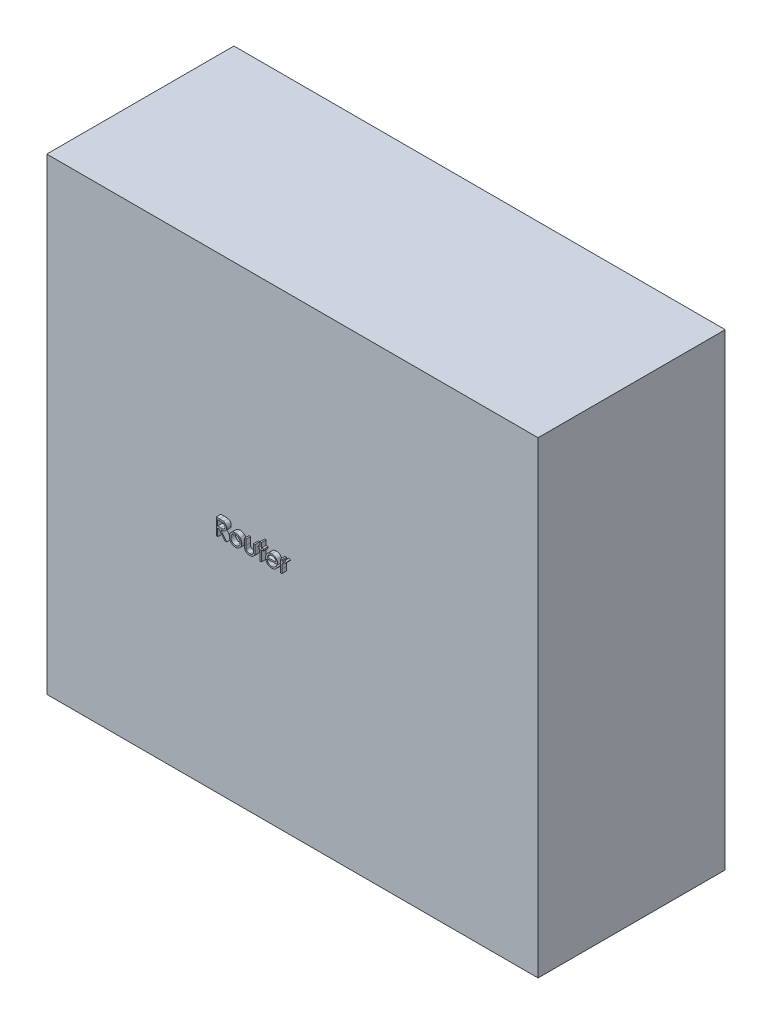
from build123d import *

# Parameters (mm, degrees)
SKETCH1_W           = 105
SKETCH1_H           = 100
BOSS_EXTRUDE1_DEPTH = 40
BOSS_EXTRUDE2_DEPTH = 1


with BuildPart() as part:
    # Sketch1 → Boss-Extrude1 (new body)
    with BuildSketch(Plane.XY):
        Rectangle(SKETCH1_W, SKETCH1_H)
    extrude(amount=BOSS_EXTRUDE1_DEPTH)

    # Sketch4 → Boss-Extrude2 (add)
    with BuildSketch(Plane.XY.offset(40)):
        with BuildLine():
            Line((-15.273233296, 1.946566312), (-14.572812623, 1.946566312))
            add(Edge.make_bspline(
                [(-14.572812623, 1.946566312), (-14.526071494, 1.946410726), (-14.43632335, 1.946111984), (-14.307750079, 1.944446221), (-14.190922982, 1.939671865), (-14.085903143, 1.935563282), (-13.992692488, 1.92807134), (-13.911005197, 1.920910693), (-13.8412175, 1.911537032), (-13.798971648, 1.902831609), (-13.779843873, 1.89889003)],
                knots=[0, 0, 0, 0, 0.000140226, 0.00026925, 0.000385712, 0.000490995, 0.000584507, 0.000666202, 0.000736998, 0.000795574, 0.000795574, 0.000795574, 0.000795574], degree=3))
            add(Edge.make_bspline(
                [(-13.779843873, 1.89889003), (-13.754237248, 1.892563265), (-13.703570259, 1.880044701), (-13.630620193, 1.8535851), (-13.561105869, 1.822965476), (-13.495316045, 1.787001755), (-13.433580254, 1.745426976), (-13.375261943, 1.698958853), (-13.320096479, 1.647851647), (-13.270314849, 1.590816806), (-13.223375797, 1.530980296), (-13.183787171, 1.466276539), (-13.149660691, 1.398615012), (-13.122490174, 1.327307594), (-13.100612201, 1.253045822), (-13.085185961, 1.175157025), (-13.075934774, 1.09399605), (-13.074992918, 1.038638142), (-13.074515347, 1.010568716)],
                knots=[0, 0, 0, 0, 7.9081e-05, 0.000156475, 0.000232432, 0.000306798, 0.00038108, 0.000455429, 0.000530331, 0.000606314, 0.000682321, 0.000758201, 0.000833453, 0.000909362, 0.000986794, 0.001065445, 0.001147284, 0.001231465, 0.001231465, 0.001231465, 0.001231465], degree=3))
            add(Edge.make_bspline(
                [(-13.074515347, 1.010568716), (-13.075984345, 0.963933611), (-13.078850741, 0.872936443), (-13.105575845, 0.740875562), (-13.149352364, 0.617686247), (-13.209675653, 0.503523609), (-13.286495129, 0.400612964), (-13.37881992, 0.310222509), (-13.486701532, 0.234582596), (-13.587130848, 0.182129791), (-13.675845047, 0.148536883), (-13.74887836, 0.124900524), (-13.828545338, 0.106638559), (-13.914082672, 0.090278427), (-14.005846328, 0.077926733), (-14.103616367, 0.068880138), (-14.207462519, 0.063226089), (-14.278801588, 0.062384084), (-14.315500924, 0.061950927)],
                knots=[0, 0, 0, 0, 0.000139777, 0.000272741, 0.000402249, 0.000530843, 0.000658588, 0.000786009, 0.000916741, 0.001052522, 0.001124656, 0.001201155, 0.001282612, 0.001369656, 0.001462366, 0.001560247, 0.001664165, 0.001774261, 0.001774261, 0.001774261, 0.001774261], degree=3))
            Line((-14.315500924, 0.061950927), (-13.029643552, -1.553433688))
            Line((-13.029643552, -1.553433688), (-13.418065026, -1.553433688))
            Line((-13.418065026, -1.553433688), (-14.703922398, 0.061950927))
            Line((-14.703922398, 0.061950927), (-14.959130732, 0.061950927))
            Line((-14.959130732, 0.061950927), (-14.959130732, -1.553433688))
            Line((-14.959130732, -1.553433688), (-15.273233296, -1.553433688))
            Line((-15.273233296, -1.553433688), (-15.273233296, 1.946566312))
        make_face()
        with BuildLine():
            Line((-14.959130732, 1.587591953), (-14.959130732, 0.420925286))
            Line((-14.959130732, 0.420925286), (-14.318305411, 0.416017434))
            add(Edge.make_bspline(
                [(-14.318305411, 0.416017434), (-14.288385372, 0.416004197), (-14.230391815, 0.415978541), (-14.14649115, 0.419972317), (-14.068371039, 0.424515635), (-13.996330286, 0.431464981), (-13.930336711, 0.440421053), (-13.870423298, 0.451624037), (-13.816492246, 0.464676099), (-13.753593708, 0.484877725), (-13.683357176, 0.516883743), (-13.607025716, 0.563449242), (-13.542023379, 0.622018361), (-13.487105516, 0.688991817), (-13.442976085, 0.762628066), (-13.41186403, 0.842044435), (-13.392121588, 0.925236033), (-13.389793043, 0.982414141), (-13.388617911, 1.011269838)],
                knots=[0, 0, 0, 0, 8.9746e-05, 0.000173954, 0.000251933, 0.000324488, 0.000391021, 0.000451663, 0.000507268, 0.000557378, 0.000649639, 0.000738152, 0.000824558, 0.000910739, 0.000997194, 0.001080909, 0.00116578, 0.001252248, 0.001252248, 0.001252248, 0.001252248], degree=3))
            add(Edge.make_bspline(
                [(-13.388617911, 1.011269838), (-13.389820032, 1.039416411), (-13.392202198, 1.09519265), (-13.411650966, 1.17684856), (-13.444540347, 1.253915511), (-13.488862585, 1.326079996), (-13.54286174, 1.391585731), (-13.606179553, 1.447632884), (-13.677084748, 1.493882349), (-13.743355946, 1.52343673), (-13.802590159, 1.541556583), (-13.854019819, 1.554307747), (-13.912131297, 1.564552216), (-13.977206755, 1.572760276), (-14.048968386, 1.579815221), (-14.127779037, 1.584566999), (-14.213115817, 1.587380863), (-14.272262749, 1.587519952), (-14.302880732, 1.587591953)],
                knots=[0, 0, 0, 0, 8.4371e-05, 0.000167192, 0.000250141, 0.000334794, 0.000420435, 0.000503871, 0.000587493, 0.000673488, 0.0007205, 0.000773215, 0.000832351, 0.0008974, 0.000969955, 0.001048634, 0.001134217, 0.001226067, 0.001226067, 0.001226067, 0.001226067], degree=3))
            Line((-14.302880732, 1.587591953), (-14.959130732, 1.587591953))
        make_face(mode=Mode.SUBTRACT)
        with BuildLine():
            add(Edge.make_bspline(
                [(-11.166061821, 1.049130415), (-11.118070548, 1.048108523), (-11.023971391, 1.046104845), (-10.886163505, 1.024689879), (-10.754618369, 0.991942515), (-10.628832177, 0.946670953), (-10.510415881, 0.885989002), (-10.397644637, 0.813579711), (-10.290827629, 0.727797117), (-10.226804599, 0.661439049), (-10.194307014, 0.627756216)],
                knots=[0, 0, 0, 0, 0.000143868, 0.000282091, 0.000417278, 0.000550139, 0.000682145, 0.000815559, 0.000951665, 0.001091969, 0.001091969, 0.001091969, 0.001091969], degree=3))
            add(Edge.make_bspline(
                [(-10.194307014, 0.627756216), (-10.16632506, 0.59554223), (-10.110902679, 0.531737688), (-10.039836961, 0.428282075), (-9.9786154, 0.321141974), (-9.929552439, 0.208894648), (-9.890867416, 0.092519977), (-9.863401719, -0.028382035), (-9.847064785, -0.153544382), (-9.844861818, -0.23854822), (-9.843746116, -0.281598752)],
                knots=[0, 0, 0, 0, 0.000127922, 0.000253368, 0.000375813, 0.000497617, 0.000620225, 0.000743195, 0.000869033, 0.000998161, 0.000998161, 0.000998161, 0.000998161], degree=3))
            add(Edge.make_bspline(
                [(-9.843746116, -0.281598752), (-9.844727454, -0.32489881), (-9.846666622, -0.410461743), (-9.865010238, -0.536481109), (-9.893541324, -0.658675932), (-9.934373162, -0.776534625), (-9.986731272, -0.890417453), (-10.050621959, -0.999827002), (-10.126493576, -1.104979135), (-10.212497573, -1.204980974), (-10.307549449, -1.297147188), (-10.410665597, -1.377475458), (-10.519819631, -1.446296982), (-10.636462984, -1.501733398), (-10.759530471, -1.545443098), (-10.889287539, -1.576143115), (-11.02553261, -1.594704798), (-11.118559831, -1.597088372), (-11.166061821, -1.598305483)],
                knots=[0, 0, 0, 0, 0.000129829, 0.000256548, 0.000381202, 0.000505812, 0.000630045, 0.000756669, 0.000885282, 0.001018518, 0.001151902, 0.001281775, 0.001409974, 0.001538236, 0.001668405, 0.001801048, 0.001937587, 0.002080055, 0.002080055, 0.002080055, 0.002080055], degree=3))
            add(Edge.make_bspline(
                [(-11.166061821, -1.598305483), (-11.213796541, -1.597084287), (-11.307287401, -1.594692512), (-11.444013382, -1.576215229), (-11.574003001, -1.545457247), (-11.6972316, -1.501589754), (-11.814376447, -1.44629521), (-11.924162944, -1.377683521), (-12.027362859, -1.297123366), (-12.122434844, -1.204987428), (-12.208433449, -1.104977472), (-12.284306457, -0.999827434), (-12.348196784, -0.89041734), (-12.400554987, -0.776534655), (-12.4413868, -0.658675923), (-12.469917893, -0.536481111), (-12.488261508, -0.410461742), (-12.490200676, -0.32489881), (-12.491182014, -0.281598752)],
                knots=[0, 0, 0, 0, 0.000143168, 0.000280402, 0.000413045, 0.000543214, 0.000672108, 0.000800903, 0.000930775, 0.00106416, 0.001197395, 0.001326009, 0.001452632, 0.001576866, 0.001701476, 0.00182613, 0.001952849, 0.002082678, 0.002082678, 0.002082678, 0.002082678], degree=3))
            add(Edge.make_bspline(
                [(-12.491182014, -0.281598752), (-12.490058703, -0.238782206), (-12.487834742, -0.154012804), (-12.471514233, -0.029085743), (-12.444155676, 0.091611646), (-12.40542428, 0.207537122), (-12.355909089, 0.319292558), (-12.295547801, 0.426697389), (-12.223757168, 0.529685189), (-12.168555217, 0.593407269), (-12.140621116, 0.625652851)],
                knots=[0, 0, 0, 0, 0.000128428, 0.000254265, 0.000377235, 0.000499178, 0.000620341, 0.000743397, 0.000868267, 0.000996189, 0.000996189, 0.000996189, 0.000996189], degree=3))
            add(Edge.make_bspline(
                [(-12.140621116, 0.625652851), (-12.108172525, 0.65962779), (-12.044356661, 0.726445486), (-11.937007934, 0.81197801), (-11.824514112, 0.885894084), (-11.704789186, 0.945370299), (-11.579106328, 0.992208817), (-11.446887086, 1.024774332), (-11.30861157, 1.046027687), (-11.214051949, 1.048085865), (-11.166061821, 1.049130415)],
                knots=[0, 0, 0, 0, 0.000140798, 0.000276904, 0.000410699, 0.000543958, 0.000677061, 0.000812248, 0.000951858, 0.001095726, 0.001095726, 0.001095726, 0.001095726], degree=3))
        make_face()
        with BuildLine():
            add(Edge.make_bspline(
                [(-11.167464065, 0.735027851), (-11.201401676, 0.734063259), (-11.268400805, 0.732158976), (-11.36702039, 0.717675072), (-11.461960544, 0.694727567), (-11.553401388, 0.662123511), (-11.64103456, 0.620024612), (-11.724943963, 0.568316252), (-11.805376402, 0.507683296), (-11.880758466, 0.438220624), (-11.949940778, 0.362341629), (-12.010418755, 0.281493271), (-12.061843861, 0.196986924), (-12.10468402, 0.108734713), (-12.136591208, 0.015842299), (-12.15976423, -0.080638332), (-12.174234471, -0.180903748), (-12.176120849, -0.249064767), (-12.17707945, -0.283702117)],
                knots=[0, 0, 0, 0, 0.000101781, 0.000200935, 0.000298373, 0.000394396, 0.000491609, 0.000589491, 0.000689611, 0.000793323, 0.000896562, 0.000997243, 0.001095722, 0.001192936, 0.001290943, 0.001389744, 0.001490285, 0.001594167, 0.001594167, 0.001594167, 0.001594167], degree=3))
            add(Edge.make_bspline(
                [(-12.17707945, -0.283702117), (-12.175472626, -0.328454145), (-12.172283381, -0.41727855), (-12.146348145, -0.548089673), (-12.102961865, -0.673671525), (-12.044374585, -0.793287911), (-11.970968367, -0.903960189), (-11.8844813, -1.002631673), (-11.7858416, -1.087817485), (-11.6762251, -1.15849833), (-11.557870782, -1.214658086), (-11.43261446, -1.254457062), (-11.301973766, -1.280328754), (-11.212693035, -1.282900228), (-11.167464065, -1.284202919)],
                knots=[0, 0, 0, 0, 0.000134178, 0.000266319, 0.000398243, 0.00053182, 0.000664828, 0.000795487, 0.000924236, 0.001054533, 0.001185628, 0.001316003, 0.001448011, 0.001583547, 0.001583547, 0.001583547, 0.001583547], degree=3))
            add(Edge.make_bspline(
                [(-11.167464065, -1.284202919), (-11.122237696, -1.282892638), (-11.0329621, -1.280306182), (-10.902502923, -1.254587362), (-10.777588951, -1.214483701), (-10.659357564, -1.158561491), (-10.54979096, -1.087549077), (-10.450441839, -1.003112699), (-10.364693228, -0.903698848), (-10.291359623, -0.793141319), (-10.23181288, -0.673856967), (-10.188629678, -0.548066495), (-10.162632093, -0.417284453), (-10.159451264, -0.328456122), (-10.15784868, -0.283702117)],
                knots=[0, 0, 0, 0, 0.000135536, 0.000267545, 0.000397252, 0.000528347, 0.000658644, 0.000787925, 0.000918122, 0.00105113, 0.001185017, 0.001316942, 0.001449082, 0.00158326, 0.00158326, 0.00158326, 0.00158326], degree=3))
            add(Edge.make_bspline(
                [(-10.15784868, -0.283702117), (-10.15880695, -0.24906456), (-10.160692679, -0.180903134), (-10.175167644, -0.08064068), (-10.198323184, 0.015850916), (-10.230294801, 0.108702919), (-10.272948815, 0.197215424), (-10.325365608, 0.281245151), (-10.385596633, 0.362621697), (-10.455613754, 0.437975338), (-10.530917132, 0.507710374), (-10.61138217, 0.568339764), (-10.695167149, 0.619797359), (-10.782545731, 0.6624836), (-10.873998299, 0.69443094), (-10.968805428, 0.717807572), (-11.067004238, 0.732097768), (-11.133763281, 0.73404491), (-11.167464065, 0.735027851)],
                knots=[0, 0, 0, 0, 0.000103882, 0.000204424, 0.000303225, 0.000401232, 0.000498445, 0.000597291, 0.000697972, 0.000801684, 0.000905395, 0.001005516, 0.001103397, 0.001199979, 0.001296663, 0.00139342, 0.001492573, 0.001593654, 0.001593654, 0.001593654, 0.001593654], degree=3))
        make_face(mode=Mode.SUBTRACT)
        with BuildLine():
            Line((-9.260412783, 1.00425862), (-8.946310219, 1.00425862))
            Line((-8.946310219, 1.00425862), (-8.946310219, -0.182039457))
            add(Edge.make_bspline(
                [(-8.946310219, -0.182039457), (-8.946168314, -0.216862206), (-8.945896856, -0.283476494), (-8.944055916, -0.379331681), (-8.939725822, -0.466748394), (-8.934311997, -0.545777131), (-8.927349861, -0.616404522), (-8.919066501, -0.678383879), (-8.909808079, -0.732418063), (-8.900745365, -0.764961419), (-8.896530571, -0.780096348)],
                knots=[0, 0, 0, 0, 0.00010447, 0.000199845, 0.000287586, 0.000367011, 0.000437473, 0.000500438, 0.00055462, 0.000601725, 0.000601725, 0.000601725, 0.000601725], degree=3))
            add(Edge.make_bspline(
                [(-8.896530571, -0.780096348), (-8.889769116, -0.799119219), (-8.876386775, -0.83676948), (-8.852113292, -0.891158485), (-8.822084955, -0.941533768), (-8.789225127, -0.989837841), (-8.751325719, -1.034639827), (-8.708866248, -1.075864071), (-8.663268011, -1.115068162), (-8.595512988, -1.161452954), (-8.502853722, -1.211168285), (-8.381200967, -1.254064103), (-8.249296741, -1.279699923), (-8.158132021, -1.282674178), (-8.111274161, -1.284202919)],
                knots=[0, 0, 0, 0, 6.0561e-05, 0.000119863, 0.000178304, 0.000236261, 0.000294971, 0.000353969, 0.000413668, 0.000475127, 0.000599968, 0.00072792, 0.000860749, 0.001001226, 0.001001226, 0.001001226, 0.001001226], degree=3))
            add(Edge.make_bspline(
                [(-8.111274161, -1.284202919), (-8.064420653, -1.28264167), (-7.973767785, -1.279620943), (-7.843312816, -1.254837404), (-7.724061401, -1.213431715), (-7.61721045, -1.155624304), (-7.52324461, -1.084882241), (-7.444940191, -1.001873432), (-7.380332937, -0.909224045), (-7.352123516, -0.840099766), (-7.337936821, -0.805336733)],
                knots=[0, 0, 0, 0, 0.000140477, 0.000271796, 0.000396637, 0.000517726, 0.000634816, 0.00074789, 0.000858929, 0.000971266, 0.000971266, 0.000971266, 0.000971266], degree=3))
            add(Edge.make_bspline(
                [(-7.337936821, -0.805336733), (-7.333742591, -0.791370434), (-7.324470173, -0.760494359), (-7.314507821, -0.70811461), (-7.30553336, -0.645650006), (-7.297870184, -0.572691797), (-7.292405021, -0.489430645), (-7.289458994, -0.395892569), (-7.286130719, -0.292371208), (-7.286080203, -0.219903449), (-7.286053809, -0.182039457)],
                knots=[0, 0, 0, 0, 4.3723e-05, 9.6661e-05, 0.000159723, 0.000233047, 0.000316669, 0.000409984, 0.000513788, 0.000627372, 0.000627372, 0.000627372, 0.000627372], degree=3))
            Line((-7.286053809, -0.182039457), (-7.286053809, 1.00425862))
            Line((-7.286053809, 1.00425862), (-6.971951244, 1.00425862))
            Line((-6.971951244, 1.00425862), (-6.971951244, -0.240933688))
            add(Edge.make_bspline(
                [(-6.971951244, -0.240933688), (-6.972392939, -0.283240859), (-6.973249888, -0.365322559), (-6.978757231, -0.484606671), (-6.988206844, -0.595768916), (-7.002549529, -0.698868136), (-7.019415203, -0.793825617), (-7.041171476, -0.880763063), (-7.067149714, -0.959412617), (-7.096455229, -1.031154394), (-7.131077097, -1.096201288), (-7.167904117, -1.157937105), (-7.210428889, -1.21483004), (-7.255199123, -1.269712177), (-7.305000779, -1.319853705), (-7.358900638, -1.366405181), (-7.416140058, -1.410078212), (-7.477989256, -1.449169492), (-7.543545319, -1.484386137), (-7.612889176, -1.515602215), (-7.686870174, -1.540304792), (-7.764533811, -1.561615458), (-7.84626059, -1.578329927), (-7.931971723, -1.590116494), (-8.02163834, -1.597341825), (-8.082747799, -1.59797887), (-8.114078648, -1.598305483)],
                knots=[0, 0, 0, 0, 0.00012692, 0.000246243, 0.000358153, 0.000461473, 0.000558423, 0.000647357, 0.000730057, 0.000806749, 0.000879504, 0.000950929, 0.001022168, 0.001092368, 0.001163264, 0.001233837, 0.001305913, 0.001379045, 0.001453076, 0.001529034, 0.001606858, 0.001686798, 0.001770538, 0.001856901, 0.001946219, 0.002040193, 0.002040193, 0.002040193, 0.002040193], degree=3))
            add(Edge.make_bspline(
                [(-8.114078648, -1.598305483), (-8.145175162, -1.597965776), (-8.206282707, -1.59729822), (-8.295953952, -1.590156412), (-8.381902558, -1.578348241), (-8.463822957, -1.561493024), (-8.541797354, -1.540453954), (-8.616141594, -1.515450418), (-8.685985157, -1.484369937), (-8.752167161, -1.449392379), (-8.814169549, -1.409827104), (-8.872278127, -1.366459064), (-8.92641498, -1.319353001), (-8.976592048, -1.268705644), (-9.022105024, -1.213888708), (-9.063521066, -1.155343147), (-9.101477771, -1.093649059), (-9.135830561, -1.027585896), (-9.165342317, -0.955013886), (-9.191397563, -0.874716789), (-9.212708201, -0.785814273), (-9.23005067, -0.688382344), (-9.24400211, -0.582887302), (-9.253688252, -0.468718887), (-9.259104083, -0.346155195), (-9.259967145, -0.261505305), (-9.260412783, -0.217796669)],
                knots=[0, 0, 0, 0, 9.3273e-05, 0.00018329, 0.000269653, 0.000353393, 0.000434009, 0.000511834, 0.000588433, 0.000663082, 0.000736214, 0.00080885, 0.000880413, 0.000951309, 0.001022496, 0.001093894, 0.001166283, 0.00123966, 0.001317, 0.001401032, 0.001492689, 0.001591018, 0.001697812, 0.001811817, 0.001934642, 0.002065769, 0.002065769, 0.002065769, 0.002065769], degree=3))
            Line((-9.260412783, -0.217796669), (-9.260412783, 1.00425862))
        make_face()
        Polygon((-5.939899962, 2.036309902), (-5.625797398, 2.036309902), (-5.625797398, 1.00425862), (-5.17707945, 1.00425862), (-5.17707945, 0.690156056), (-5.625797398, 0.690156056), (-5.625797398, -1.553433688), (-5.939899962, -1.553433688), (-5.939899962, 0.690156056), (-6.388617911, 0.690156056), (-6.388617911, 1.00425862), (-5.939899962, 1.00425862), align=None)
        with BuildLine():
            Line((-2.539459257, -0.74574138), (-2.260412783, -0.892275835))
            add(Edge.make_bspline(
                [(-2.260412783, -0.892275835), (-2.282649378, -0.931719167), (-2.325912987, -1.008460269), (-2.400313734, -1.11389213), (-2.478305807, -1.208739846), (-2.563409775, -1.2904695), (-2.653079454, -1.361720885), (-2.747812109, -1.42405871), (-2.848100927, -1.47717723), (-2.953950651, -1.521929758), (-3.066250202, -1.556339252), (-3.185271719, -1.580643473), (-3.311243214, -1.595666742), (-3.397589394, -1.597411882), (-3.441803007, -1.598305483)],
                knots=[0, 0, 0, 0, 0.000135759, 0.000264133, 0.000386579, 0.000503597, 0.000617365, 0.000729763, 0.000843304, 0.000957371, 0.001074023, 0.001195027, 0.001321389, 0.001453992, 0.001453992, 0.001453992, 0.001453992], degree=3))
            add(Edge.make_bspline(
                [(-3.441803007, -1.598305483), (-3.490944985, -1.597158307), (-3.586806746, -1.594920501), (-3.726346494, -1.575628036), (-3.857725912, -1.544155678), (-3.980937615, -1.500190136), (-4.095679868, -1.442762812), (-4.202180723, -1.37280333), (-4.301000249, -1.290671076), (-4.389024458, -1.195654632), (-4.46826834, -1.093972675), (-4.53819416, -0.98801679), (-4.596651591, -0.878053566), (-4.644204202, -0.764783042), (-4.682609067, -0.648919148), (-4.70937577, -0.529407681), (-4.724805518, -0.406572096), (-4.727169964, -0.323474761), (-4.728361501, -0.281598752)],
                knots=[0, 0, 0, 0, 0.000147371, 0.000287478, 0.000421649, 0.000552053, 0.000679042, 0.000805636, 0.000933558, 0.00106351, 0.001193382, 0.001319977, 0.001443869, 0.001566405, 0.001688128, 0.001809576, 0.001933238, 0.002058864, 0.002058864, 0.002058864, 0.002058864], degree=3))
            add(Edge.make_bspline(
                [(-4.728361501, -0.281598752), (-4.727302359, -0.242303922), (-4.725203281, -0.164426757), (-4.711972494, -0.049161212), (-4.688524201, 0.06286724), (-4.656347877, 0.171751688), (-4.614796631, 0.277309822), (-4.563964411, 0.379605886), (-4.503772034, 0.478531026), (-4.45729936, 0.540934159), (-4.433890347, 0.572367594)],
                knots=[0, 0, 0, 0, 0.000117891, 0.000233644, 0.000347498, 0.000460856, 0.000573868, 0.000687374, 0.000803169, 0.000920699, 0.000920699, 0.000920699, 0.000920699], degree=3))
            add(Edge.make_bspline(
                [(-4.433890347, 0.572367594), (-4.402182664, 0.610236464), (-4.339771718, 0.684774615), (-4.234215362, 0.78271294), (-4.119915166, 0.864756716), (-3.99830354, 0.932763852), (-3.867967066, 0.984437499), (-3.730657775, 1.022945081), (-3.584812188, 1.044523092), (-3.485106968, 1.047570926), (-3.434090667, 1.049130415)],
                knots=[0, 0, 0, 0, 0.000148071, 0.000291452, 0.00043058, 0.000569298, 0.000708346, 0.00085021, 0.000996268, 0.001149307, 0.001149307, 0.001149307, 0.001149307], degree=3))
            add(Edge.make_bspline(
                [(-3.434090667, 1.049130415), (-3.381643062, 1.047776366), (-3.278752816, 1.04512003), (-3.128720695, 1.020493697), (-2.986759979, 0.981441142), (-2.852927474, 0.926287352), (-2.727209614, 0.8551278), (-2.610423564, 0.766985959), (-2.500572051, 0.664567871), (-2.436663473, 0.585804662), (-2.404142751, 0.545724966)],
                knots=[0, 0, 0, 0, 0.000157241, 0.00030847, 0.000454763, 0.000598116, 0.000741606, 0.000886879, 0.001036172, 0.001190853, 0.001190853, 0.001190853, 0.001190853], degree=3))
            add(Edge.make_bspline(
                [(-2.404142751, 0.545724966), (-2.382015813, 0.515521385), (-2.337909219, 0.455315266), (-2.282662119, 0.357144109), (-2.234704724, 0.254433514), (-2.196371763, 0.145523217), (-2.165332262, 0.031703637), (-2.142875443, -0.087838908), (-2.129705825, -0.213068819), (-2.127117128, -0.298395374), (-2.125797398, -0.341895226)],
                knots=[0, 0, 0, 0, 0.000112234, 0.000223721, 0.000337279, 0.000451932, 0.000569628, 0.000690912, 0.000816421, 0.00094695, 0.00094695, 0.00094695, 0.00094695], degree=3))
            Line((-2.125797398, -0.341895226), (-4.414258937, -0.341895226))
            add(Edge.make_bspline(
                [(-4.414258937, -0.341895226), (-4.41271933, -0.375595691), (-4.409691756, -0.441866294), (-4.395576613, -0.538837077), (-4.373327839, -0.63121042), (-4.342058777, -0.718293462), (-4.304191932, -0.801223589), (-4.257806215, -0.879385626), (-4.202466661, -0.952423556), (-4.140740961, -1.020990694), (-4.072033866, -1.082051455), (-3.999751119, -1.136703231), (-3.922857554, -1.182508828), (-3.84195947, -1.219688718), (-3.757187685, -1.248795034), (-3.66851549, -1.268662854), (-3.576117374, -1.281969961), (-3.51313164, -1.283449626), (-3.481065828, -1.284202919)],
                knots=[0, 0, 0, 0, 0.000101159, 0.000198924, 0.000293472, 0.000385722, 0.000476069, 0.000566611, 0.000657757, 0.000750573, 0.000842919, 0.000933083, 0.001022062, 0.001110842, 0.001199752, 0.001290403, 0.001383113, 0.001479259, 0.001479259, 0.001479259, 0.001479259], degree=3))
            add(Edge.make_bspline(
                [(-3.481065828, -1.284202919), (-3.44971468, -1.283594862), (-3.387507989, -1.282388361), (-3.294867132, -1.27065645), (-3.203727604, -1.251686174), (-3.114466621, -1.225796184), (-3.028895775, -1.194219332), (-2.949650225, -1.156116475), (-2.87677001, -1.113966728), (-2.808653043, -1.065757053), (-2.74258205, -1.006748866), (-2.677039563, -0.933113145), (-2.60676291, -0.846025617), (-2.562773317, -0.780479951), (-2.539459257, -0.74574138)],
                knots=[0, 0, 0, 0, 9.4016e-05, 0.000186545, 0.000279636, 0.000373054, 0.000465125, 0.000552934, 0.000636508, 0.000717442, 0.000802858, 0.000901616, 0.001012865, 0.001138311, 0.001138311, 0.001138311, 0.001138311], degree=3))
        make_face()
        with BuildLine():
            add(Edge.make_bspline(
                [(-2.439899962, -0.027792662), (-2.451396587, 0.013870211), (-2.473523888, 0.094057832), (-2.519760253, 0.205098722), (-2.571831794, 0.303786623), (-2.633453525, 0.389366257), (-2.703272251, 0.465369769), (-2.783917433, 0.531788355), (-2.874353327, 0.591205806), (-2.974112467, 0.641358305), (-3.079754252, 0.684048164), (-3.190360444, 0.71267328), (-3.303218232, 0.732282822), (-3.379552519, 0.73410893), (-3.417964866, 0.735027851)],
                knots=[0, 0, 0, 0, 0.000129543, 0.000249328, 0.000360065, 0.000463575, 0.000564789, 0.000668832, 0.000776175, 0.000888744, 0.001003316, 0.001117263, 0.001230914, 0.001346035, 0.001346035, 0.001346035, 0.001346035], degree=3))
            add(Edge.make_bspline(
                [(-3.417964866, 0.735027851), (-3.449314305, 0.734416179), (-3.511285554, 0.733207033), (-3.602586622, 0.721736904), (-3.690266321, 0.702777059), (-3.774971609, 0.676812102), (-3.855592477, 0.6422035), (-3.933787245, 0.601620273), (-4.007567641, 0.552078689), (-4.053708937, 0.514319834), (-4.077019353, 0.495244197)],
                knots=[0, 0, 0, 0, 9.4016e-05, 0.000185849, 0.000275511, 0.000362884, 0.000451173, 0.00053836, 0.000626838, 0.000717174, 0.000717174, 0.000717174, 0.000717174], degree=3))
            add(Edge.make_bspline(
                [(-4.077019353, 0.495244197), (-4.093712635, 0.480149881), (-4.12749577, 0.449602665), (-4.172636291, 0.396973458), (-4.215856764, 0.340221896), (-4.255190417, 0.277176772), (-4.291268003, 0.208555993), (-4.32502798, 0.134938357), (-4.355414392, 0.055765227), (-4.372510502, 0.000592788), (-4.381306212, -0.027792662)],
                knots=[0, 0, 0, 0, 6.7454e-05, 0.00013651, 0.000207604, 0.000281328, 0.000359112, 0.000440057, 0.000524171, 0.000613305, 0.000613305, 0.000613305, 0.000613305], degree=3))
            Line((-4.381306212, -0.027792662), (-2.439899962, -0.027792662))
        make_face(mode=Mode.SUBTRACT)
        with BuildLine():
            Line((-1.58733586, 1.00425862), (-1.273233296, 1.00425862))
            Line((-1.273233296, 1.00425862), (-1.273233296, 0.627756216))
            add(Edge.make_bspline(
                [(-1.273233296, 0.627756216), (-1.250044537, 0.662812044), (-1.205696216, 0.729856044), (-1.131983287, 0.818525345), (-1.056479955, 0.891940391), (-0.978824768, 0.95044391), (-0.898446668, 0.994257029), (-0.817109716, 1.026350064), (-0.733534247, 1.045327379), (-0.677372322, 1.047861038), (-0.649234898, 1.049130415)],
                knots=[0, 0, 0, 0, 0.000126023, 0.000241017, 0.000345147, 0.000441342, 0.00053171, 0.000618946, 0.000702978, 0.000787349, 0.000787349, 0.000787349, 0.000787349], degree=3))
            add(Edge.make_bspline(
                [(-0.649234898, 1.049130415), (-0.627408572, 1.047939888), (-0.582499487, 1.045490302), (-0.514516897, 1.028279478), (-0.444473445, 1.000801455), (-0.399331058, 0.974961232), (-0.375797398, 0.96149019)],
                knots=[0, 0, 0, 0, 6.5445e-05, 0.000134658, 0.00020926, 0.000290509, 0.000290509, 0.000290509, 0.000290509], degree=3))
            Line((-0.375797398, 0.96149019), (-0.54827336, 0.689454934))
            add(Edge.make_bspline(
                [(-0.54827336, 0.689454934), (-0.563382381, 0.6961952), (-0.592062195, 0.708989515), (-0.634016762, 0.724131526), (-0.672698098, 0.733047441), (-0.697341657, 0.734398159), (-0.708830251, 0.735027851)],
                knots=[0, 0, 0, 0, 4.9621e-05, 9.4191e-05, 0.00013366, 0.000168129, 0.000168129, 0.000168129, 0.000168129], degree=3))
            add(Edge.make_bspline(
                [(-0.708830251, 0.735027851), (-0.734035984, 0.733347813), (-0.785448374, 0.729921024), (-0.860932874, 0.702982216), (-0.934180079, 0.659456976), (-0.992351742, 0.611185864), (-1.037393994, 0.564638067), (-1.06953422, 0.523989664), (-1.099016967, 0.478411033), (-1.127187187, 0.428681349), (-1.152853482, 0.373951503), (-1.176808151, 0.314768289), (-1.198467014, 0.251063161), (-1.210817258, 0.20668064), (-1.217143552, 0.18394612)],
                knots=[0, 0, 0, 0, 7.549e-05, 0.000153978, 0.000237553, 0.000330197, 0.000379784, 0.000431685, 0.000485357, 0.000542493, 0.000603021, 0.000666557, 0.00073396, 0.000804745, 0.000804745, 0.000804745, 0.000804745], degree=3))
            add(Edge.make_bspline(
                [(-1.217143552, 0.18394612), (-1.221875945, 0.163668946), (-1.232357837, 0.118756548), (-1.242549375, 0.043408023), (-1.252618893, -0.045615636), (-1.259715511, -0.148562229), (-1.266293553, -0.265174673), (-1.270003636, -0.395630618), (-1.273106776, -0.54006397), (-1.273189843, -0.641038323), (-1.273233296, -0.693858367)],
                knots=[0, 0, 0, 0, 6.2435e-05, 0.000138289, 0.000227871, 0.000331224, 0.000447781, 0.000578258, 0.000722716, 0.000881171, 0.000881171, 0.000881171, 0.000881171], degree=3))
            Line((-1.273233296, -0.693858367), (-1.273233296, -1.553433688))
            Line((-1.273233296, -1.553433688), (-1.58733586, -1.553433688))
            Line((-1.58733586, -1.553433688), (-1.58733586, 1.00425862))
        make_face()
    extrude(amount=BOSS_EXTRUDE2_DEPTH)


solid = part.part
